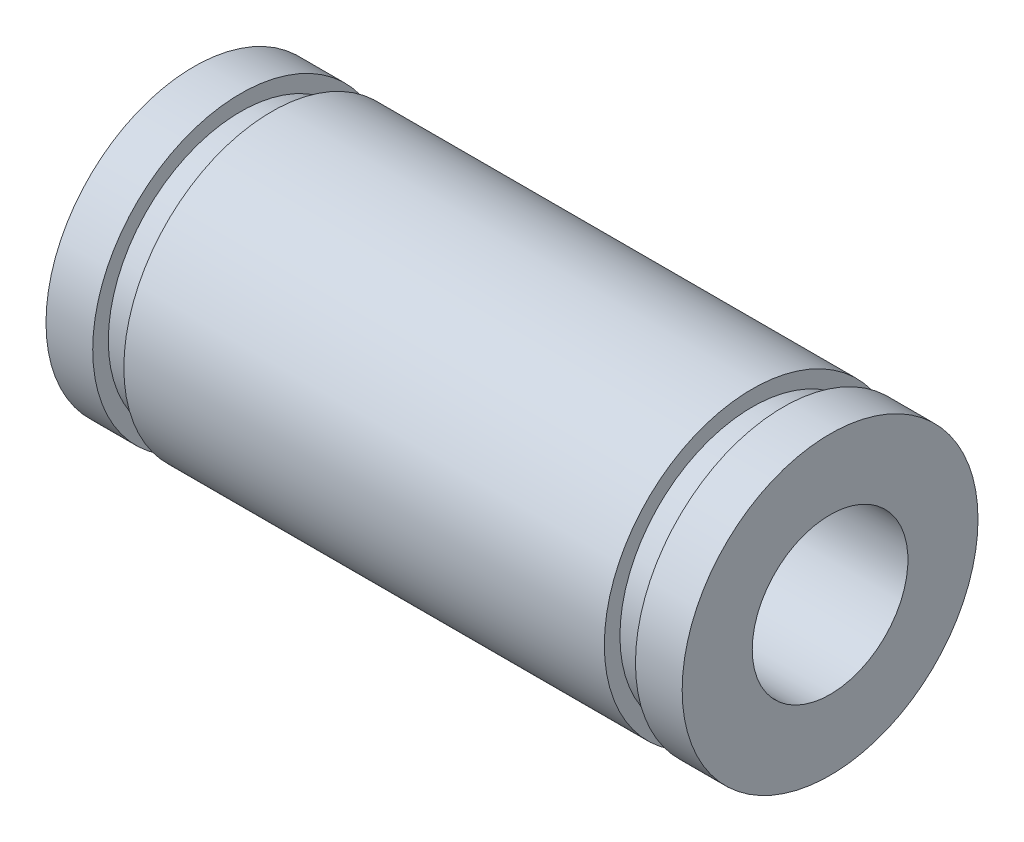
from build123d import *


with BuildPart() as part:
    # Sketch1 → Revolve1 (revolve)
    with BuildSketch(Plane.XY):
        Polygon((-17.953807762, 9.5), (-14.953807762, 9.5), (-14.953807762, 8.497591784), (-12.953807762, 8.497591784), (-12.953807762, 9.5), (17.90509788, 9.5), (17.90509788, 8.497591784), (19.90509788, 8.497591784), (19.90509788, 9.5), (22.90509788, 9.5), (22.90509788, 5), (-17.953807762, 5), align=None)
    revolve(axis=Axis((-38.753770095, 0, 0), (1, 0, 0)))


solid = part.part
